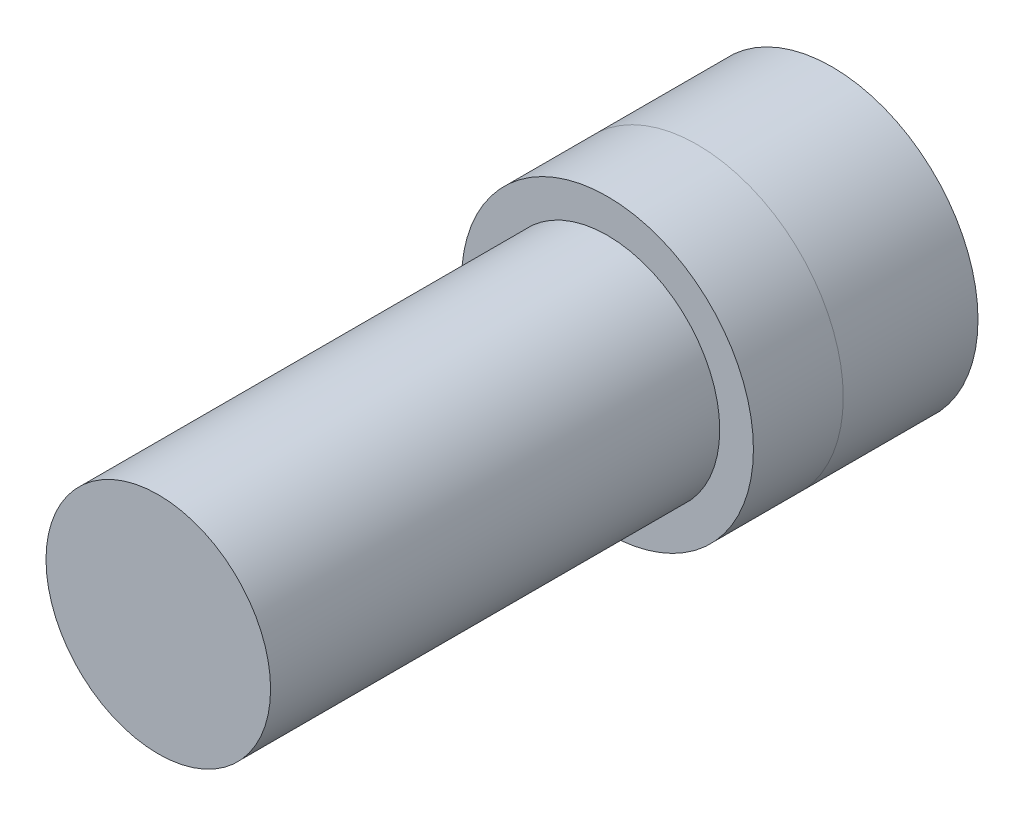
from build123d import *

# Parameters (mm, degrees)
ESQUISSE1_R             = 6.5
BOSS_EXTRU_1_DEPTH      = 10
ESQUISSE2_R             = 5
BOSS_EXTRU_2_DEPTH      = 20
ESQUISSE3_R             = 6.5
ENL_V_MAT_EXTRU_1_DEPTH = 6
ESQUISSE5_R             = 6.5
BOSS_EXTRU_4_DEPTH      = 6


with BuildPart() as part:
    # Esquisse1 → Boss.-Extru.1 (new body)
    with BuildSketch(Plane.XY):
        Circle(ESQUISSE1_R)
    extrude(amount=BOSS_EXTRU_1_DEPTH)

    # Esquisse2 → Boss.-Extru.2 (add)
    with BuildSketch(Plane.XY.offset(10)):
        Circle(ESQUISSE2_R)
    extrude(amount=BOSS_EXTRU_2_DEPTH)

    # Esquisse3 → Enlèv. mat.-Extru.1 (cut)
    with BuildSketch(Plane(origin=(0, 0, 0), x_dir=(-1, 0, 0), z_dir=(0, 0, -1))):
        Circle(ESQUISSE3_R)
    extrude(amount=-ENL_V_MAT_EXTRU_1_DEPTH, mode=Mode.SUBTRACT)


with BuildPart() as body_2:
    # Esquisse5 → Boss.-Extru.4 (new body)
    with BuildSketch(Plane(origin=(0, 0, 6), x_dir=(-1, 0, 0), z_dir=(0, 0, -1))):
        Circle(ESQUISSE5_R)
    extrude(amount=BOSS_EXTRU_4_DEPTH)


solid = Compound([part.part, body_2.part])
